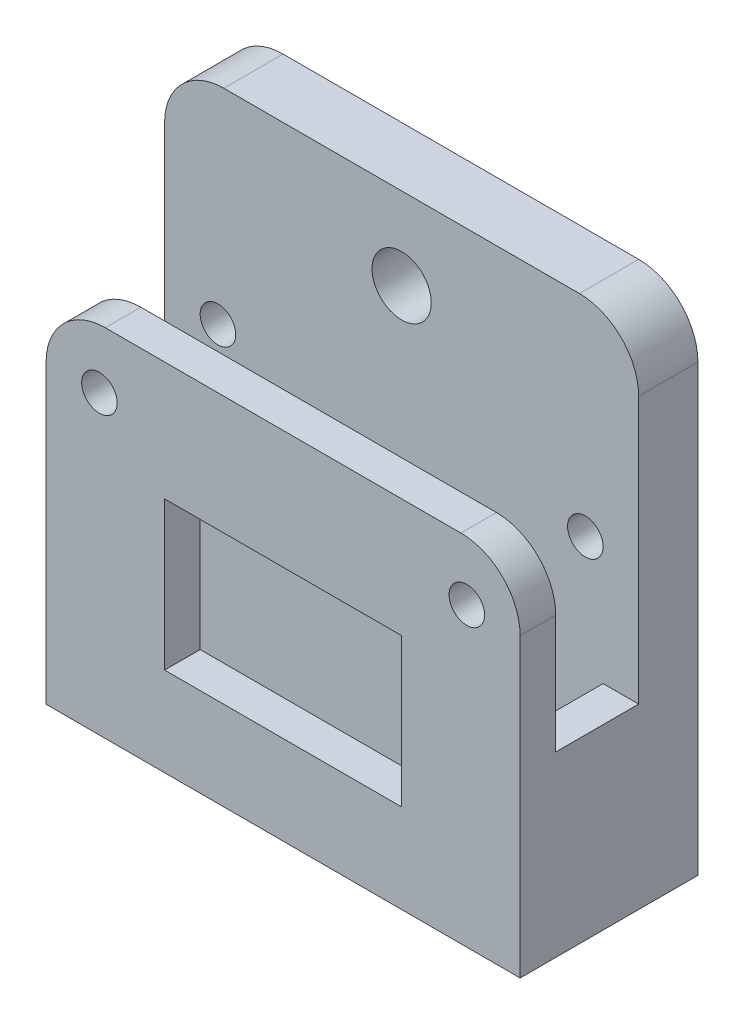
from build123d import *

# Parameters (mm, degrees)
SKETCH1_W           = 40
SKETCH1_H           = 50
BOSS_EXTRUDE2_DEPTH = 15
SKETCH2_W           = 34
SKETCH2_H           = 7
CUT_EXTRUDE1_DEPTH  = 50
SKETCH3_W           = 7
SKETCH3_H           = 30
CUT_EXTRUDE2_DEPTH  = 50
SKETCH6_W           = 40
SKETCH6_H           = 2.5
SKETCH6_H_2         = 4.98530806
CUT_EXTRUDE4_DEPTH  = 50
SKETCH7_W           = 40
SKETCH7_H           = 12.5
CUT_EXTRUDE5_DEPTH  = 5
SKETCH8_W           = 20
SKETCH8_H           = 12.51469194
CUT_EXTRUDE7_DEPTH  = 5
SKETCH11_R          = 2.5
CUT_EXTRUDE10_DEPTH = 5
SKETCH12_R          = 1.5
CUT_EXTRUDE11_DEPTH = 15
FILLET2_R           = 5
FILLET3_R           = 5


with BuildPart() as part:
    # Sketch1 → Boss-Extrude2 (new body)
    with BuildSketch(Plane.XY):
        with Locations((400.458722726, 329.091279026)):
            Rectangle(SKETCH1_W, SKETCH1_H)
    extrude(amount=BOSS_EXTRUDE2_DEPTH)

    # Sketch2 → Cut-Extrude1 (cut)
    with BuildSketch(Plane(origin=(0, 354.091279026, 0), x_dir=(1, 0, 0), z_dir=(0, 1, 0))):
        with Locations((400.458722726, -8.5)):
            Rectangle(SKETCH2_W, SKETCH2_H)
    extrude(amount=-CUT_EXTRUDE1_DEPTH, mode=Mode.SUBTRACT)

    # Sketch3 → Cut-Extrude2 (cut)
    with BuildSketch(Plane.ZY.offset(-380.458722726)):
        with Locations((8.5, 339.091279026)):
            Rectangle(SKETCH3_W, SKETCH3_H)
    extrude(amount=-CUT_EXTRUDE2_DEPTH, mode=Mode.SUBTRACT)

    # Sketch6 → Cut-Extrude4 (cut)
    with BuildSketch(Plane(origin=(0, 0, 0), x_dir=(-1, 0, 0), z_dir=(0, 0, -1))):
        with Locations((-400.458722726, 352.841279026)):
            Rectangle(SKETCH6_W, SKETCH6_H)
        with Locations((-400.458722726, 306.583933056)):
            Rectangle(SKETCH6_W, SKETCH6_H_2)
    extrude(amount=-CUT_EXTRUDE4_DEPTH, mode=Mode.SUBTRACT)

    # Sketch7 → Cut-Extrude5 (cut)
    with BuildSketch(Plane.XY.offset(15)):
        with Locations((400.458722726, 345.341279026)):
            Rectangle(SKETCH7_W, SKETCH7_H)
    extrude(amount=-CUT_EXTRUDE5_DEPTH, mode=Mode.SUBTRACT)

    # Sketch8 → Cut-Extrude7 (cut)
    with BuildSketch(Plane.XY.offset(15)):
        with Locations((400.458722726, 322.833933056)):
            Rectangle(SKETCH8_W, SKETCH8_H)
    extrude(amount=-CUT_EXTRUDE7_DEPTH, mode=Mode.SUBTRACT)

    # Sketch11 → Cut-Extrude10 (cut)
    with BuildSketch(Plane.XY.offset(5)):
        with Locations((400.458722726, 344.660615353)):
            Circle(SKETCH11_R)
        with Locations((400.458722726, 322.932953385)):
            Circle(SKETCH11_R)
    extrude(amount=-CUT_EXTRUDE10_DEPTH, mode=Mode.SUBTRACT)

    # Sketch12 → Cut-Extrude11 (cut)
    with BuildSketch(Plane.XY.offset(15)):
        with Locations((415.958722726, 334.091279026)):
            Circle(SKETCH12_R)
        with Locations((384.958722726, 334.091279026)):
            Circle(SKETCH12_R)
    extrude(amount=-CUT_EXTRUDE11_DEPTH, mode=Mode.SUBTRACT)

    # Fillet2
    fillet2_edges = [part.edges().sort_by_distance(p)[0] for p in [
        (380.458722726, 339.091279026, 13.5),
    ]]
    fillet(fillet2_edges, radius=FILLET2_R)

    # Fillet3
    fillet3_edges = [part.edges().sort_by_distance(p)[0] for p in [
        (420.458722726, 339.091279026, 13.5),
        (380.458722726, 351.591279026, 2.5),
        (420.458722726, 351.591279026, 2.5),
    ]]
    fillet(fillet3_edges, radius=FILLET3_R)


solid = part.part
